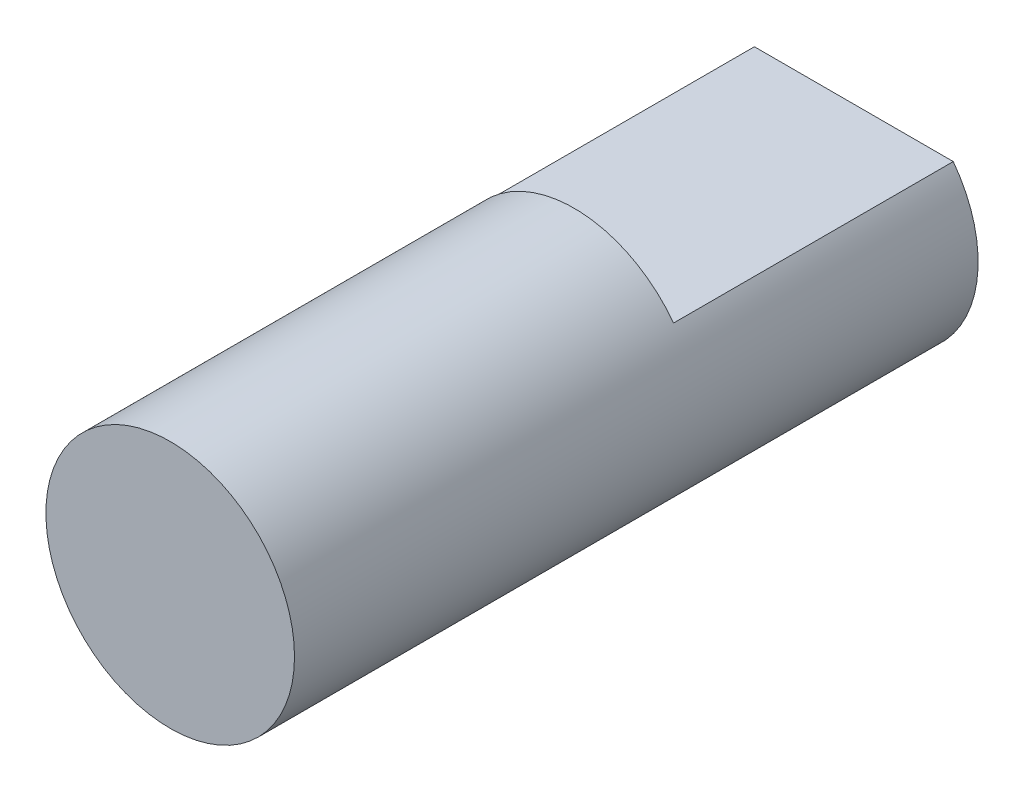
from build123d import *

# Parameters (mm, degrees)
CROQUIS1_R              = 4
SALIENTE_EXTRUIR1_DEPTH = 11
CORTAR_EXTRUIR1_DEPTH   = 9


with BuildPart() as part:
    # Croquis1 → Saliente-Extruir1 (new body, symmetric)
    with BuildSketch(Plane.XY):
        Circle(CROQUIS1_R)
    extrude(amount=SALIENTE_EXTRUIR1_DEPTH, both=True)

    # Croquis2 → Cortar-Extruir1 (cut)
    with BuildSketch(Plane(origin=(0, 0, -11), x_dir=(-1, 0, 0), z_dir=(0, 0, -1))):
        with BuildLine():
            Line((-3.2, 2.4), (3.2, 2.4))
            ThreePointArc((3.2, 2.4), (0, 4), (-3.2, 2.4))
        make_face()
    extrude(amount=-CORTAR_EXTRUIR1_DEPTH, mode=Mode.SUBTRACT)


solid = part.part
